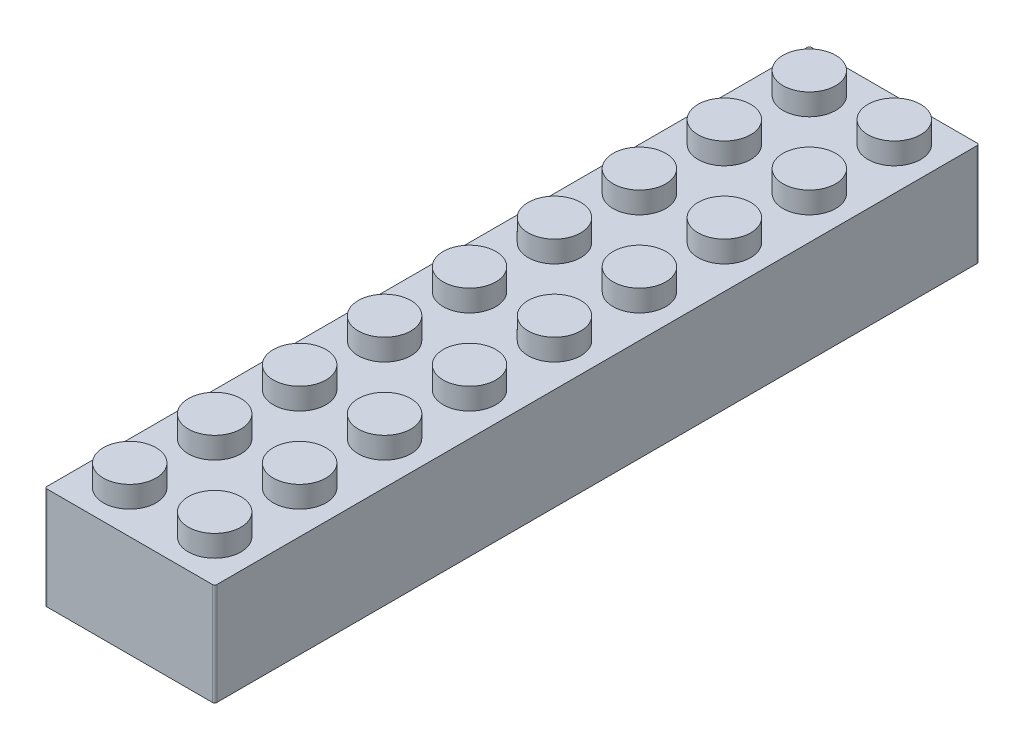
from build123d import *

# Parameters (mm, degrees)
SKETCH1_W           = 15.8
SKETCH1_H           = 71.1
BOSS_EXTRUDE1_DEPTH = 4.75
SKETCH2_R           = 2.45
BOSS_EXTRUDE2_DEPTH = 2
SKETCH3_W           = 12.8
SKETCH3_H           = 68.1
CUT_EXTRUDE1_DEPTH  = 4
SKETCH4_R           = 3.25
SKETCH4_R_2         = 2.45
BOSS_EXTRUDE3_DEPTH = 4
FILLET1_R           = 0.2


with BuildPart() as part:
    # Sketch1 → Boss-Extrude1 (new body, symmetric)
    with BuildSketch(Plane(origin=(0, 0, 0), x_dir=(1, 0, 0), z_dir=(0, 1, 0))):
        with Locations((7.9, 35.55)):
            Rectangle(SKETCH1_W, SKETCH1_H)
    extrude(amount=BOSS_EXTRUDE1_DEPTH, both=True)

    # Sketch2 → Boss-Extrude2 (add)
    with BuildSketch(Plane(origin=(0, 4.75, 0), x_dir=(1, 0, 0), z_dir=(0, 1, 0))):
        with Locations((3.95, 3.95)):
            Circle(SKETCH2_R)
        with Locations((11.85, 3.95)):
            Circle(SKETCH2_R)
        with Locations((11.85, 11.85)):
            Circle(SKETCH2_R)
        with Locations((3.95, 11.85)):
            Circle(SKETCH2_R)
        with Locations((3.95, 19.75)):
            Circle(SKETCH2_R)
        with Locations((3.95, 27.65)):
            Circle(SKETCH2_R)
        with Locations((11.85, 27.65)):
            Circle(SKETCH2_R)
        with Locations((11.85, 35.55)):
            Circle(SKETCH2_R)
        with Locations((3.95, 35.55)):
            Circle(SKETCH2_R)
        with Locations((3.95, 43.45)):
            Circle(SKETCH2_R)
        with Locations((11.85, 43.45)):
            Circle(SKETCH2_R)
        with Locations((3.95, 51.35)):
            Circle(SKETCH2_R)
        with Locations((11.85, 51.35)):
            Circle(SKETCH2_R)
        with Locations((3.95, 59.25)):
            Circle(SKETCH2_R)
        with Locations((11.85, 59.25)):
            Circle(SKETCH2_R)
        with Locations((3.95, 67.15)):
            Circle(SKETCH2_R)
        with Locations((11.85, 67.15)):
            Circle(SKETCH2_R)
        with Locations((11.85, 19.75)):
            Circle(SKETCH2_R)
    extrude(amount=BOSS_EXTRUDE2_DEPTH)

    # Sketch3 → Cut-Extrude1 (cut)
    with BuildSketch(Plane.XZ.offset(4.75)):
        with Locations((7.9, -35.55)):
            Rectangle(SKETCH3_W, SKETCH3_H)
    extrude(amount=-CUT_EXTRUDE1_DEPTH, mode=Mode.SUBTRACT)

    # Sketch4 → Boss-Extrude3 (add)
    with BuildSketch(Plane.XZ.offset(0.75)):
        with Locations((7.9, -63.2)):
            Circle(SKETCH4_R)
        with Locations((7.9, -63.2)):
            Circle(SKETCH4_R_2, mode=Mode.SUBTRACT)
        with Locations((7.9, -55.3)):
            Circle(SKETCH4_R)
        with Locations((7.9, -55.3)):
            Circle(SKETCH4_R_2, mode=Mode.SUBTRACT)
        with Locations((7.9, -47.4)):
            Circle(SKETCH4_R)
        with Locations((7.9, -47.4)):
            Circle(SKETCH4_R_2, mode=Mode.SUBTRACT)
        with Locations((7.9, -39.5)):
            Circle(SKETCH4_R)
        with Locations((7.9, -39.5)):
            Circle(SKETCH4_R_2, mode=Mode.SUBTRACT)
        with Locations((7.9, -31.6)):
            Circle(SKETCH4_R)
        with Locations((7.9, -31.6)):
            Circle(SKETCH4_R_2, mode=Mode.SUBTRACT)
        with Locations((7.9, -23.7)):
            Circle(SKETCH4_R)
        with Locations((7.9, -23.7)):
            Circle(SKETCH4_R_2, mode=Mode.SUBTRACT)
        with Locations((7.9, -15.8)):
            Circle(SKETCH4_R)
        with Locations((7.9, -15.8)):
            Circle(SKETCH4_R_2, mode=Mode.SUBTRACT)
        with Locations((7.9, -7.9)):
            Circle(SKETCH4_R)
        with Locations((7.9, -7.9)):
            Circle(SKETCH4_R_2, mode=Mode.SUBTRACT)
    extrude(amount=BOSS_EXTRUDE3_DEPTH)

    # Fillet1
    fillet1_edges = [part.edges().sort_by_distance(p)[0] for p in [
        (0, 0, -71.1),
        (15.8, 0, -71.1),
        (15.8, 0, 0),
        (0, 0, 0),
    ]]
    fillet(fillet1_edges, radius=FILLET1_R)


solid = part.part
